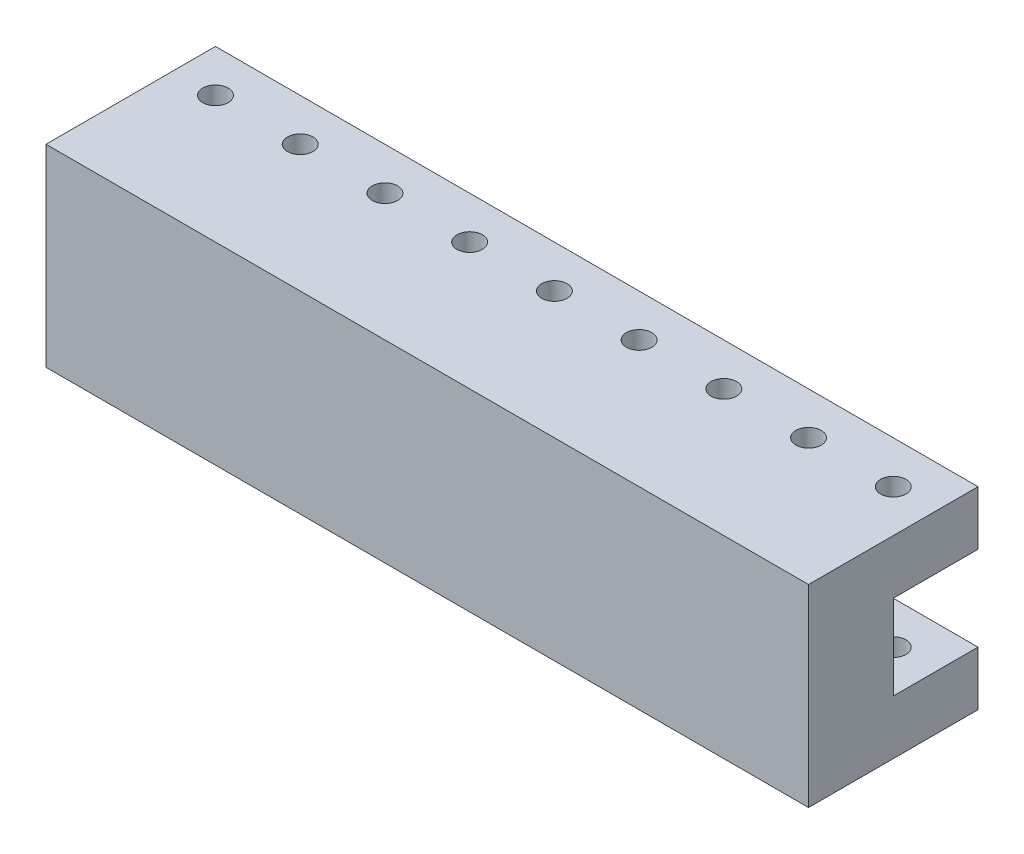
from build123d import *

# Parameters (mm, degrees)
SKETCH1_W           = 90
SKETCH1_H           = 10
BOSS_EXTRUDE1_DEPTH = 22.8
SKETCH2_R           = 1.5
CUT_EXTRUDE1_DEPTH  = 23.8
LPATTERN1_COUNT     = 9
LPATTERN1_PITCH     = 10
SKETCH3_W           = 10
SKETCH3_H           = 10
CUT_EXTRUDE2_DEPTH  = 91
SKETCH4_W           = 90
SKETCH4_H           = 22.8
BOSS_EXTRUDE2_DEPTH = 10


with BuildPart() as part:
    # Sketch1 → Boss-Extrude1 (new body)
    with BuildSketch(Plane(origin=(0, 0, 0), x_dir=(1, 0, 0), z_dir=(0, 1, 0))):
        Rectangle(SKETCH1_W, SKETCH1_H)
    extrude(amount=BOSS_EXTRUDE1_DEPTH)

    # Sketch2 → Cut-Extrude1 (cut, through all)
    with BuildSketch(Plane(origin=(0, 22.8, 0), x_dir=(1, 0, 0), z_dir=(0, 1, 0))):
        with Locations((-40, 0)):
            Circle(SKETCH2_R)
    cut_extrude1 = extrude(amount=-CUT_EXTRUDE1_DEPTH, mode=Mode.SUBTRACT)

    # LPattern1: Cut-Extrude1 ×9
    with Locations(*[(i * LPATTERN1_PITCH, 0, 0) for i in range(1, LPATTERN1_COUNT)]):
        add(cut_extrude1, mode=Mode.SUBTRACT)

    # Sketch3 → Cut-Extrude2 (cut, through all)
    with BuildSketch(Plane(origin=(45, 0, 0), x_dir=(0, 0, -1), z_dir=(1, 0, 0))):
        with Locations((0, 11.4)):
            Rectangle(SKETCH3_W, SKETCH3_H)
    extrude(amount=-CUT_EXTRUDE2_DEPTH, mode=Mode.SUBTRACT)

    # Sketch4 → Boss-Extrude2 (add)
    with BuildSketch(Plane.XY.offset(5)):
        with Locations((0, 11.4)):
            Rectangle(SKETCH4_W, SKETCH4_H)
    extrude(amount=BOSS_EXTRUDE2_DEPTH)


solid = part.part
